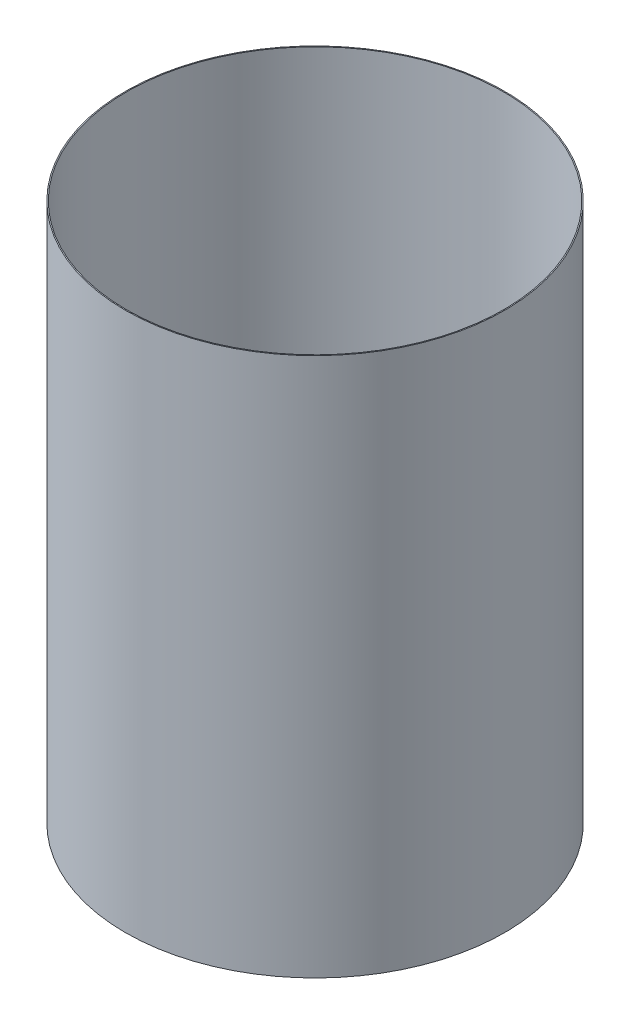
from build123d import *

# Parameters (mm, degrees)
SKETCH1_W = 0.254
SKETCH1_H = 133.35


with BuildPart() as part:
    # Sketch1 → Revolve-Thin1 (revolve)
    with BuildSketch(Plane.XY):
        with Locations((-46.7995, -86.580914232)):
            Rectangle(SKETCH1_W, SKETCH1_H)
    revolve(axis=Axis((0, 55, 0), (0, -1, 0)))


solid = part.part
